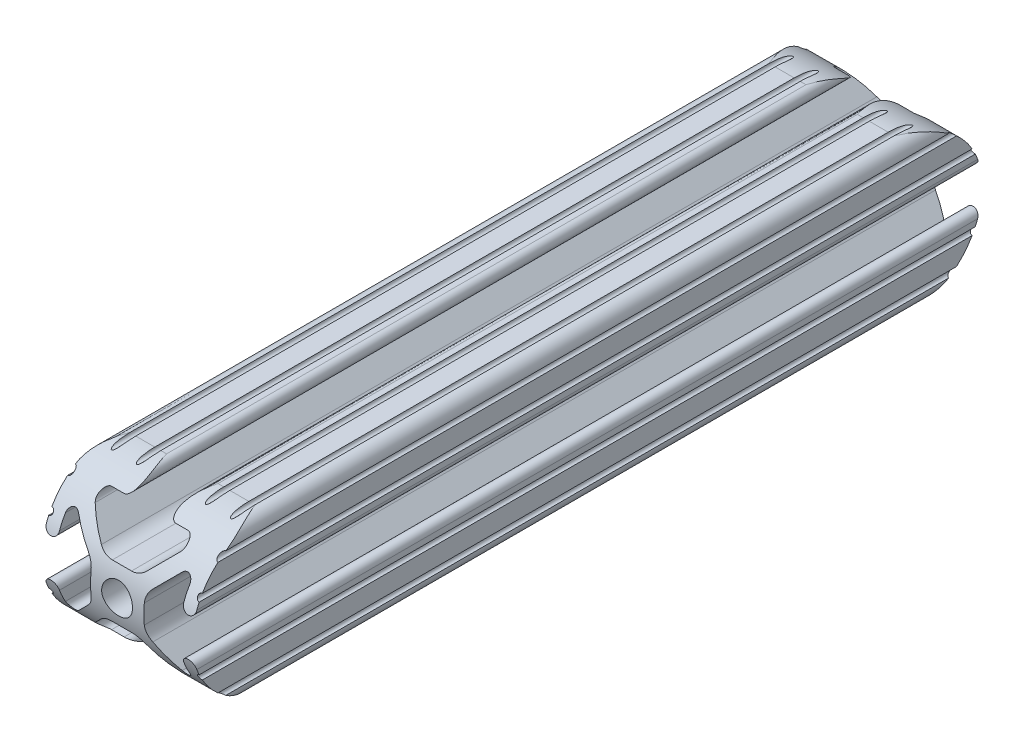
from build123d import *

# Parameters (mm, degrees)
SKETCH1_R           = 2.6035
BOSS_EXTRUDE1_DEPTH = 133.35
CUT_EXTRUDE1_DEPTH  = 26.4


with BuildPart() as part:
    # Sketch1 → Boss-Extrude1 (new body)
    with BuildSketch(Plane(origin=(0, 0, -450.85), x_dir=(-1, 0, 0), z_dir=(0, 0, -1))):
        with BuildLine():
            Line((12.7, -9.5504), (12.7, -6.3330836))
            ThreePointArc((12.7, -6.3330836), (12.192, -5.8250836), (12.7, -5.3170836))
            Line((12.7, -5.3170836), (12.7, -4.3434))
            ThreePointArc((12.7, -4.3434), (11.5951, -3.2385), (10.4902, -4.3434))
            Line((10.4902, -4.3434), (10.4902, -6.474794456))
            ThreePointArc((10.4902, -6.474794456), (9.863006367, -7.413456061), (8.75577951, -7.193214945))
            Line((8.75577951, -7.193214945), (5.42573597, -3.863171405))
            ThreePointArc((5.42573597, -3.863171405), (4.737482484, -2.833127272), (4.4958, -1.618107374))
            Line((4.4958, -1.618107374), (4.4958, 1.618107374))
            ThreePointArc((4.4958, 1.618107374), (4.737482484, 2.833127272), (5.42573597, 3.863171405))
            Line((5.42573597, 3.863171405), (8.75577951, 7.193214945))
            ThreePointArc((8.75577951, 7.193214945), (9.863006367, 7.413456061), (10.4902, 6.474794456))
            Line((10.4902, 6.474794456), (10.4902, 4.343399971))
            ThreePointArc((10.4902, 4.343399971), (11.5951, 3.238499971), (12.7, 4.343399971))
            Line((12.7, 4.343399971), (12.7, 5.3170836))
            ThreePointArc((12.7, 5.3170836), (12.192, 5.8250836), (12.7, 6.3330836))
            Line((12.7, 6.3330836), (12.7, 9.5504))
            ThreePointArc((12.7, 9.5504), (12.192000006, 10.058323491), (12.699846982, 10.566399977))
            ThreePointArc((12.699846982, 10.566399977), (12.082522516, 12.082522516), (10.566399977, 12.699846982))
            ThreePointArc((10.566399977, 12.699846982), (10.058323491, 12.192000006), (9.5504, 12.7))
            Line((9.5504, 12.7), (6.3330836, 12.7))
            ThreePointArc((6.3330836, 12.7), (5.8250836, 12.192), (5.3170836, 12.7))
            Line((5.3170836, 12.7), (4.3434, 12.7))
            ThreePointArc((4.3434, 12.7), (3.2385, 11.5951), (4.3434, 10.4902))
            Line((4.3434, 10.4902), (6.474794456, 10.4902))
            ThreePointArc((6.474794456, 10.4902), (7.413456061, 9.863006367), (7.193214945, 8.75577951))
            Line((7.193214945, 8.75577951), (3.863171405, 5.42573597))
            ThreePointArc((3.863171405, 5.42573597), (2.833127272, 4.737482484), (1.618107374, 4.4958))
            Line((1.618107374, 4.4958), (-1.618107374, 4.4958))
            ThreePointArc((-1.618107374, 4.4958), (-2.833127272, 4.737482484), (-3.863171405, 5.42573597))
            Line((-3.863171405, 5.42573597), (-7.193214945, 8.75577951))
            ThreePointArc((-7.193214945, 8.75577951), (-7.413456061, 9.863006367), (-6.474794456, 10.4902))
            Line((-6.474794456, 10.4902), (-4.343399971, 10.4902))
            ThreePointArc((-4.343399971, 10.4902), (-3.238499971, 11.5951), (-4.343399971, 12.7))
            Line((-4.343399971, 12.7), (-5.3170836, 12.7))
            ThreePointArc((-5.3170836, 12.7), (-5.8250836, 12.192), (-6.3330836, 12.7))
            Line((-6.3330836, 12.7), (-9.5504, 12.7))
            ThreePointArc((-9.5504, 12.7), (-10.058323491, 12.192000006), (-10.566399977, 12.699846982))
            ThreePointArc((-10.566399977, 12.699846982), (-12.082522516, 12.082522516), (-12.699846982, 10.566399977))
            ThreePointArc((-12.699846982, 10.566399977), (-12.192000006, 10.058323491), (-12.7, 9.5504))
            Line((-12.7, 9.5504), (-12.7, 6.3330836))
            ThreePointArc((-12.7, 6.3330836), (-12.192, 5.8250836), (-12.7, 5.3170836))
            Line((-12.7, 5.3170836), (-12.7, 4.3434))
            ThreePointArc((-12.7, 4.3434), (-11.5951, 3.2385), (-10.4902, 4.3434))
            Line((-10.4902, 4.3434), (-10.4902, 6.474794456))
            ThreePointArc((-10.4902, 6.474794456), (-9.863006367, 7.413456061), (-8.75577951, 7.193214945))
            Line((-8.75577951, 7.193214945), (-5.42573597, 3.863171405))
            ThreePointArc((-5.42573597, 3.863171405), (-4.737482484, 2.833127272), (-4.4958, 1.618107374))
            Line((-4.4958, 1.618107374), (-4.4958, -1.618107374))
            ThreePointArc((-4.4958, -1.618107374), (-4.737482484, -2.833127272), (-5.42573597, -3.863171405))
            Line((-5.42573597, -3.863171405), (-8.75577951, -7.193214945))
            ThreePointArc((-8.75577951, -7.193214945), (-9.863006367, -7.413456061), (-10.4902, -6.474794456))
            Line((-10.4902, -6.474794456), (-10.4902, -4.343399971))
            ThreePointArc((-10.4902, -4.343399971), (-11.5951, -3.238499971), (-12.7, -4.343399971))
            Line((-12.7, -4.343399971), (-12.7, -5.3170836))
            ThreePointArc((-12.7, -5.3170836), (-12.192, -5.8250836), (-12.7, -6.3330836))
            Line((-12.7, -6.3330836), (-12.7, -9.5504))
            ThreePointArc((-12.7, -9.5504), (-12.192000006, -10.058323491), (-12.699846982, -10.566399977))
            ThreePointArc((-12.699846982, -10.566399977), (-12.082522516, -12.082522516), (-10.566399977, -12.699846982))
            ThreePointArc((-10.566399977, -12.699846982), (-10.058323491, -12.192000006), (-9.5504, -12.7))
            Line((-9.5504, -12.7), (-6.3330836, -12.7))
            ThreePointArc((-6.3330836, -12.7), (-5.8250836, -12.192), (-5.3170836, -12.7))
            Line((-5.3170836, -12.7), (-4.3434, -12.7))
            ThreePointArc((-4.3434, -12.7), (-3.2385, -11.5951), (-4.3434, -10.4902))
            Line((-4.3434, -10.4902), (-6.474794456, -10.4902))
            ThreePointArc((-6.474794456, -10.4902), (-7.413456061, -9.863006367), (-7.193214945, -8.75577951))
            Line((-7.193214945, -8.75577951), (-3.863171405, -5.42573597))
            ThreePointArc((-3.863171405, -5.42573597), (-2.833127272, -4.737482484), (-1.618107374, -4.4958))
            Line((-1.618107374, -4.4958), (1.618107374, -4.4958))
            ThreePointArc((1.618107374, -4.4958), (2.833127272, -4.737482484), (3.863171405, -5.42573597))
            Line((3.863171405, -5.42573597), (7.193214945, -8.75577951))
            ThreePointArc((7.193214945, -8.75577951), (7.413456061, -9.863006367), (6.474794456, -10.4902))
            Line((6.474794456, -10.4902), (4.343399971, -10.4902))
            ThreePointArc((4.343399971, -10.4902), (3.238499971, -11.5951), (4.343399971, -12.7))
            Line((4.343399971, -12.7), (5.3170836, -12.7))
            ThreePointArc((5.3170836, -12.7), (5.8250836, -12.192), (6.3330836, -12.7))
            Line((6.3330836, -12.7), (9.5504, -12.7))
            ThreePointArc((9.5504, -12.7), (10.058323491, -12.192000006), (10.566399977, -12.699846982))
            ThreePointArc((10.566399977, -12.699846982), (12.082522516, -12.082522516), (12.699846982, -10.566399977))
            ThreePointArc((12.699846982, -10.566399977), (12.192000006, -10.058323491), (12.7, -9.5504))
        make_face()
        Circle(SKETCH1_R, mode=Mode.SUBTRACT)
    extrude(amount=-BOSS_EXTRUDE1_DEPTH)

    # Sketch3 → Cut-Extrude1 (cut, through all)
    with BuildSketch(Plane.ZY.offset(12.7)):
        with BuildLine():
            Line((-438.150153018, -12.699846982), (-438.150153018, -16.266210884))
            Line((-438.150153018, -16.266210884), (-454.387771175, -16.266210884))
            Line((-454.387771175, -16.266210884), (-454.387771175, 14.946399978))
            Line((-454.387771175, 14.946399978), (-438.150153018, 14.946399978))
            Line((-438.150153018, 14.946399978), (-438.150153018, 12.699846982))
            ThreePointArc((-438.150153018, 12.699846982), (-450.85, 0), (-438.150153018, -12.699846982))
        make_face()
        with BuildLine():
            Line((-330.2, -12.7), (-330.2, -16.266210884))
            Line((-330.2, -16.266210884), (-176.455647895, -16.266210884))
            Line((-176.455647895, -16.266210884), (-176.455647895, 14.946399978))
            Line((-176.455647895, 14.946399978), (-330.2, 14.946399978))
            Line((-330.2, 14.946399978), (-330.2, 12.7))
            ThreePointArc((-330.2, 12.7), (-317.5, 0), (-330.2, -12.7))
        make_face()
    extrude(amount=-CUT_EXTRUDE1_DEPTH, mode=Mode.SUBTRACT)


solid = part.part
